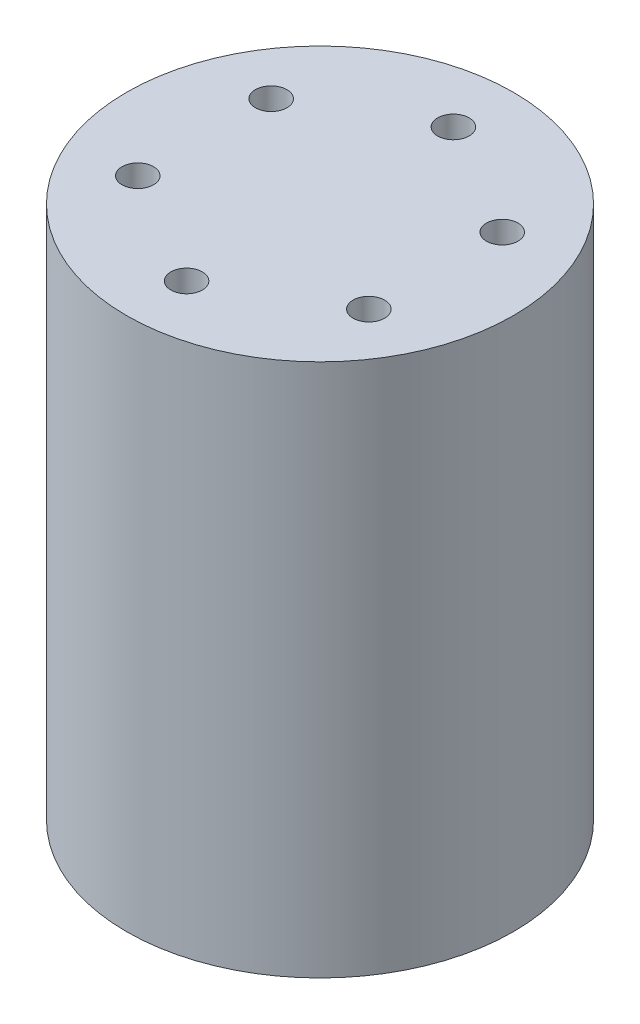
from build123d import *

# Parameters (mm, degrees)
SKETCH1_R           = 18.415
BOSS_EXTRUDE1_DEPTH = 25.4
SKETCH2_R           = 1.5
CUT_EXTRUDE1_DEPTH  = 12.7
CIRPATTERN1_COUNT   = 6


with BuildPart() as part:
    # Sketch1 → Boss-Extrude1 (new body, symmetric)
    with BuildSketch(Plane(origin=(0, 0, 0), x_dir=(1, 0, 0), z_dir=(0, 1, 0))):
        Circle(SKETCH1_R)
    extrude(amount=BOSS_EXTRUDE1_DEPTH, both=True)

    # Sketch2 → Cut-Extrude1 (cut)
    with BuildSketch(Plane(origin=(0, 25.4, 0), x_dir=(1, 0, 0), z_dir=(0, 1, 0))):
        with Locations((0, 12.7)):
            Circle(SKETCH2_R)
    cut_extrude1 = extrude(amount=-CUT_EXTRUDE1_DEPTH, mode=Mode.SUBTRACT)

    # CirPattern1: Cut-Extrude1 ×6 about axis
    cirpattern1_axis = Axis((0, 0, 0), (0, 1, 0))
    for i in range(1, CIRPATTERN1_COUNT):
        add(cut_extrude1.rotate(cirpattern1_axis, i * 360 / CIRPATTERN1_COUNT), mode=Mode.SUBTRACT)


solid = part.part
